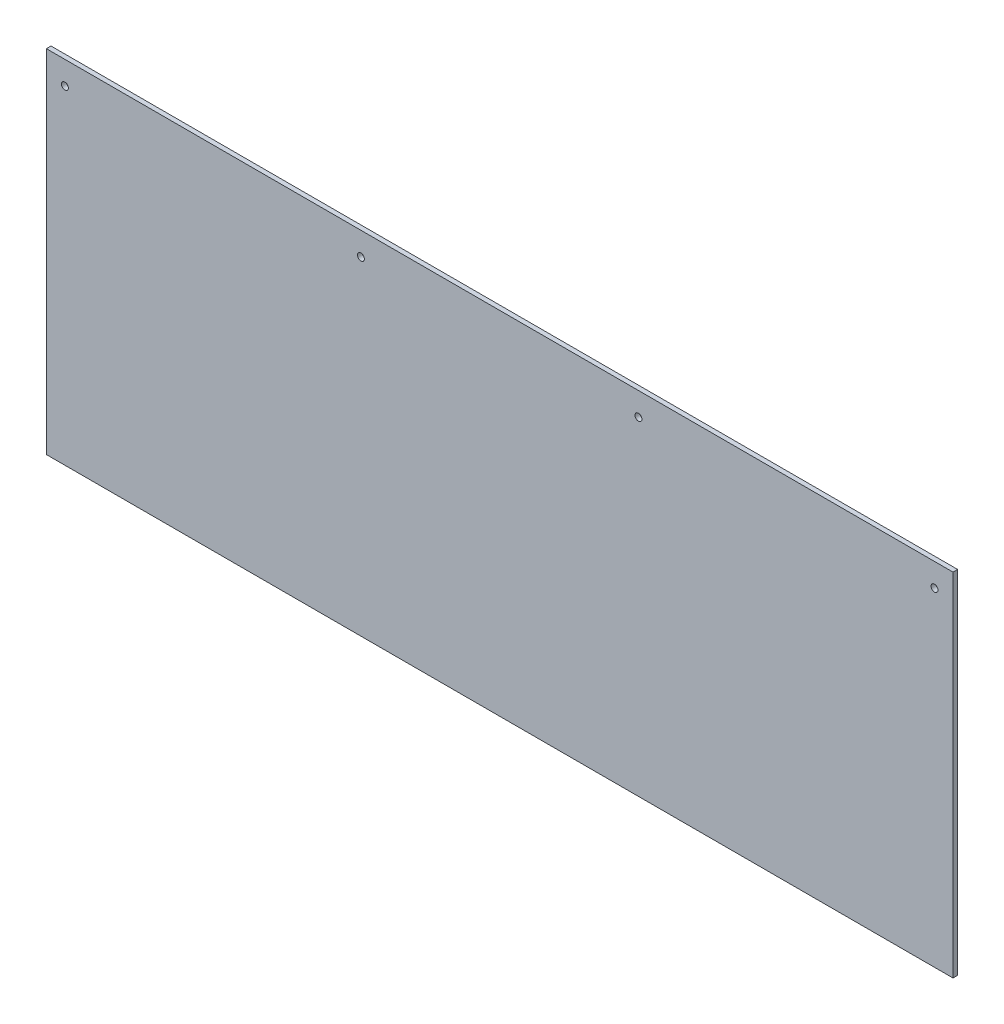
from build123d import *

# Parameters (mm, degrees)
SKETCH1_W           = 1244.6
SKETCH1_H           = 482.6
BOSS_EXTRUDE1_DEPTH = 6.35
SKETCH2_R           = 4.7625
CUT_EXTRUDE1_DEPTH  = 7.35


with BuildPart() as part:
    # Sketch1 → Boss-Extrude1 (new body)
    with BuildSketch(Plane.XY):
        with Locations((622.3, 241.3)):
            Rectangle(SKETCH1_W, SKETCH1_H)
    extrude(amount=BOSS_EXTRUDE1_DEPTH)

    # Sketch2 → Cut-Extrude1 (cut, through all)
    with BuildSketch(Plane.XY.offset(6.35)):
        with Locations((25.4, 450.85)):
            Circle(SKETCH2_R)
        with Locations((431.8, 450.85)):
            Circle(SKETCH2_R)
        with Locations((812.8, 450.85)):
            Circle(SKETCH2_R)
        with Locations((1219.2, 450.85)):
            Circle(SKETCH2_R)
    extrude(amount=-CUT_EXTRUDE1_DEPTH, mode=Mode.SUBTRACT)


solid = part.part
